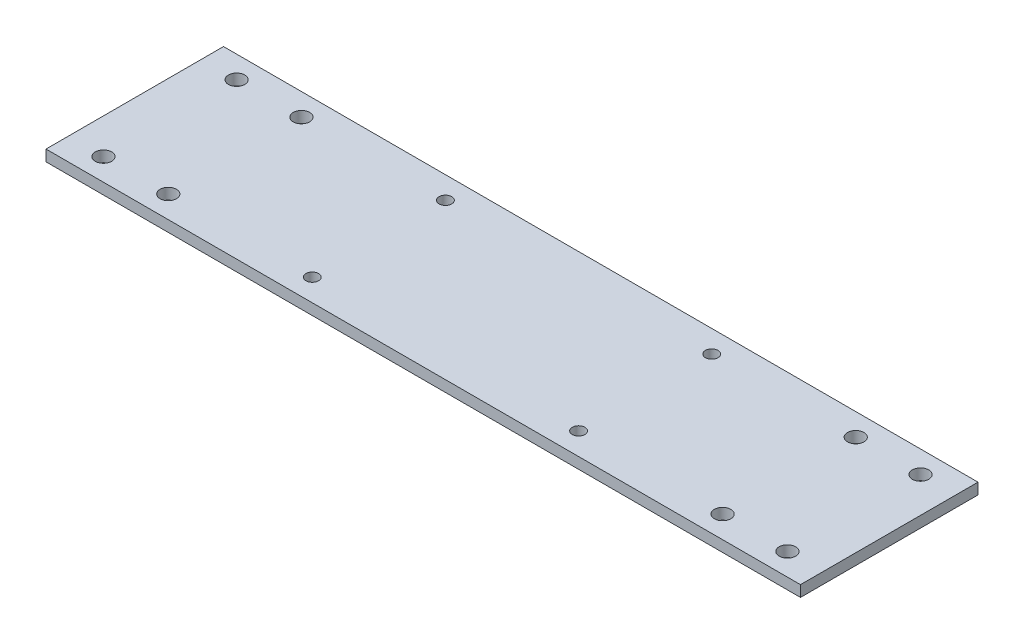
from build123d import *

# Parameters (mm, degrees)
SKETCH1_W           = 215.9
SKETCH1_H           = 50.8
SKETCH1_R           = 1.80975
BOSS_EXTRUDE1_DEPTH = 3.175
SKETCH2_R           = 2.3495
CUT_EXTRUDE1_DEPTH  = 4.175


with BuildPart() as part:
    # Sketch1 → Boss-Extrude1 (new body)
    with BuildSketch(Plane(origin=(0, 0, 0), x_dir=(1, 0, 0), z_dir=(0, 1, 0))):
        Rectangle(SKETCH1_W, SKETCH1_H)
        with Locations((-38.1, 19.05)):
            Circle(SKETCH1_R, mode=Mode.SUBTRACT)
        with Locations((-38.1, -19.05)):
            Circle(SKETCH1_R, mode=Mode.SUBTRACT)
        with Locations((38.1, 19.05)):
            Circle(SKETCH1_R, mode=Mode.SUBTRACT)
        with Locations((38.1, -19.05)):
            Circle(SKETCH1_R, mode=Mode.SUBTRACT)
    extrude(amount=BOSS_EXTRUDE1_DEPTH)

    # Sketch2 → Cut-Extrude1 (cut, through all)
    with BuildSketch(Plane(origin=(0, 3.175, 0), x_dir=(1, 0, 0), z_dir=(0, 1, 0))):
        with Locations((-97.8535, 19.05)):
            Circle(SKETCH2_R)
        with Locations((-79.3115, 19.05)):
            Circle(SKETCH2_R)
        with Locations((-79.3115, -19.05)):
            Circle(SKETCH2_R)
        with Locations((-97.8535, -19.05)):
            Circle(SKETCH2_R)
        with Locations((97.8535, -19.05)):
            Circle(SKETCH2_R)
        with Locations((79.3115, -19.05)):
            Circle(SKETCH2_R)
        with Locations((79.3115, 19.05)):
            Circle(SKETCH2_R)
        with Locations((97.8535, 19.05)):
            Circle(SKETCH2_R)
    extrude(amount=-CUT_EXTRUDE1_DEPTH, mode=Mode.SUBTRACT)


solid = part.part
